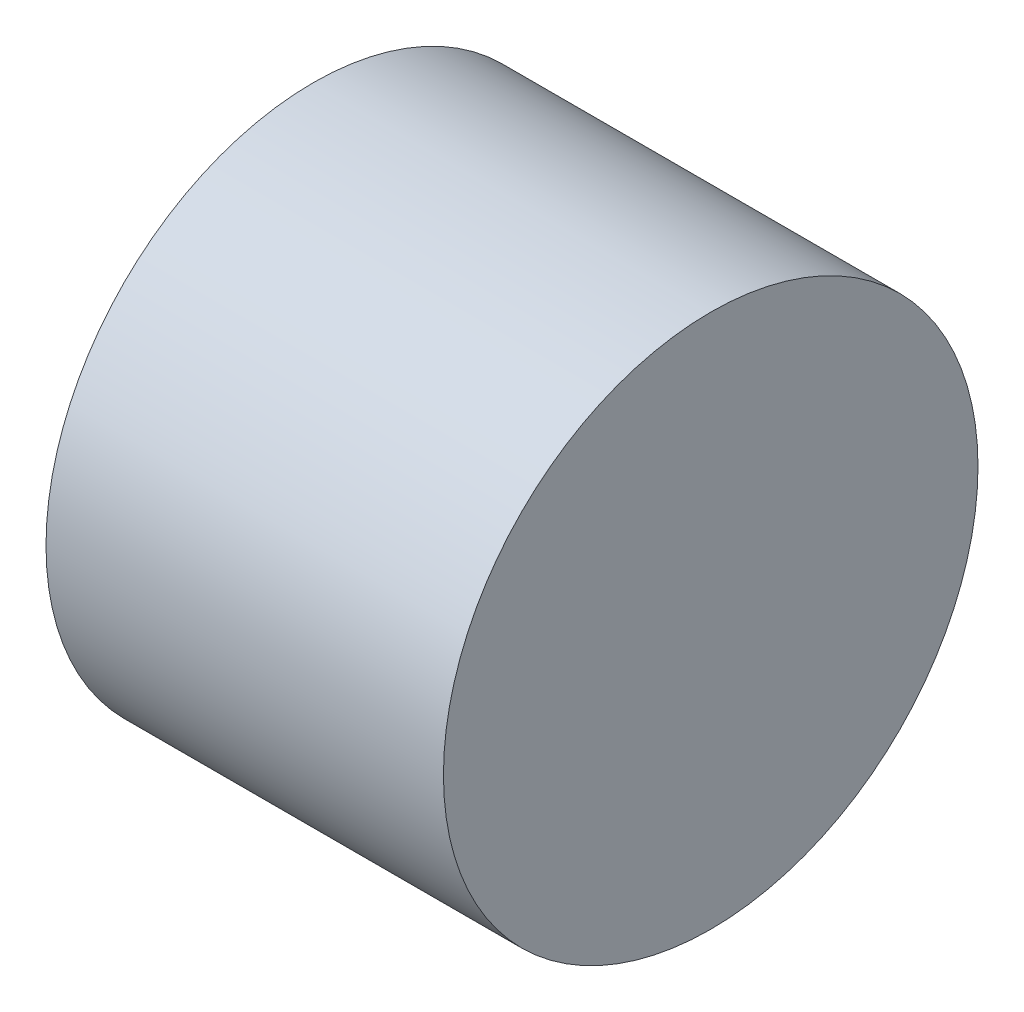
from build123d import *

# Parameters (mm, degrees)
SKETCH1_R           = 6.725
BOSS_EXTRUDE1_DEPTH = 10


with BuildPart() as part:
    # Sketch1 → Boss-Extrude1 (new body)
    with BuildSketch(Plane(origin=(0, 0, 0), x_dir=(0, 0, -1), z_dir=(1, 0, 0))):
        Circle(SKETCH1_R)
    extrude(amount=-BOSS_EXTRUDE1_DEPTH)


solid = part.part
